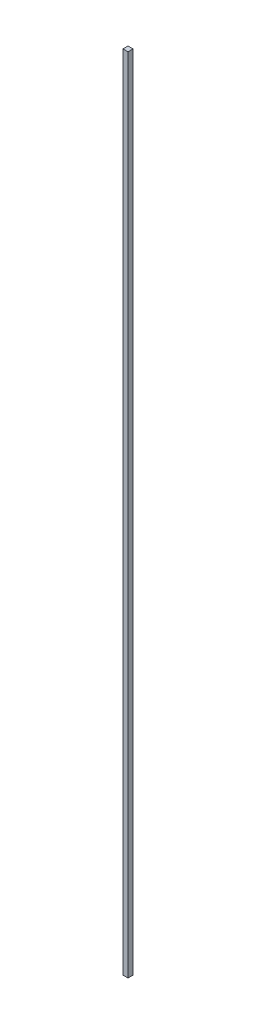
from build123d import *

# Parameters (mm, degrees)
SKETCH1_W           = 3.2
SKETCH1_H           = 3.2
BOSS_EXTRUDE2_DEPTH = 510


with BuildPart() as part:
    # Sketch1 → Boss-Extrude2 (new body)
    with BuildSketch(Plane(origin=(0, 0, 0), x_dir=(1, 0, 0), z_dir=(0, 1, 0))):
        with Locations((-1.6, -1.6)):
            Rectangle(SKETCH1_W, SKETCH1_H)
    extrude(amount=BOSS_EXTRUDE2_DEPTH)


solid = part.part
